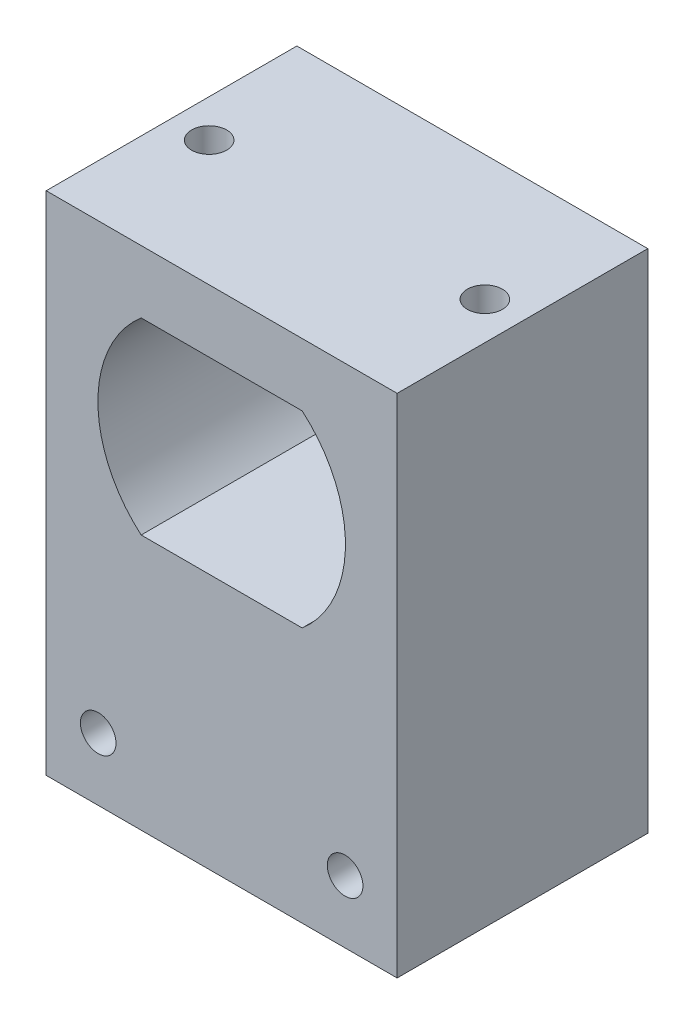
from build123d import *

# Parameters (mm, degrees)
SKETCH4_W           = 28
SKETCH4_H           = 40.4
BOSS_EXTRUDE1_DEPTH = 20
CUT_EXTRUDE1_DEPTH  = 21
SKETCH6_R           = 1.42
CUT_EXTRUDE3_DEPTH  = 10
SKETCH7_W           = 24
SKETCH7_H           = 6
CUT_EXTRUDE4_DEPTH  = 10
SKETCH8_R           = 1.4
CUT_EXTRUDE5_DEPTH  = 8


with BuildPart() as part:
    # Sketch4 → Boss-Extrude1 (new body)
    with BuildSketch(Plane.XY):
        Rectangle(SKETCH4_W, SKETCH4_H)
    extrude(amount=BOSS_EXTRUDE1_DEPTH)

    # Sketch5 → Cut-Extrude1 (cut, through all)
    with BuildSketch(Plane.XY.offset(20)):
        with BuildLine():
            Line((-6.423832579, 15.2), (6.423832579, 15.2))
            ThreePointArc((6.423832579, 15.2), (9.875, 7.7), (6.423832579, 0.2))
            Line((6.423832579, 0.2), (-6.423832579, 0.2))
            ThreePointArc((-6.423832579, 0.2), (-9.875, 7.7), (-6.423832579, 15.2))
        make_face()
    extrude(amount=-CUT_EXTRUDE1_DEPTH, mode=Mode.SUBTRACT)

    # Sketch6 → Cut-Extrude3 (cut)
    with BuildSketch(Plane.XY.offset(20)):
        with Locations((-9.85, -15.2)):
            Circle(SKETCH6_R)
        with Locations((9.85, -15.2)):
            Circle(SKETCH6_R)
    extrude(amount=-CUT_EXTRUDE3_DEPTH, mode=Mode.SUBTRACT)

    # Sketch7 → Cut-Extrude4 (cut)
    with BuildSketch(Plane.XY):
        with Locations((0, -15.2)):
            Rectangle(SKETCH7_W, SKETCH7_H)
    extrude(amount=CUT_EXTRUDE4_DEPTH, mode=Mode.SUBTRACT)

    # Sketch8 → Cut-Extrude5 (cut)
    with BuildSketch(Plane(origin=(0, 20.2, 0), x_dir=(1, 0, 0), z_dir=(0, 1, 0))):
        with Locations((-11, -10)):
            Circle(SKETCH8_R)
        with Locations((11, -10)):
            Circle(SKETCH8_R)
    extrude(amount=-CUT_EXTRUDE5_DEPTH, mode=Mode.SUBTRACT)


solid = part.part
